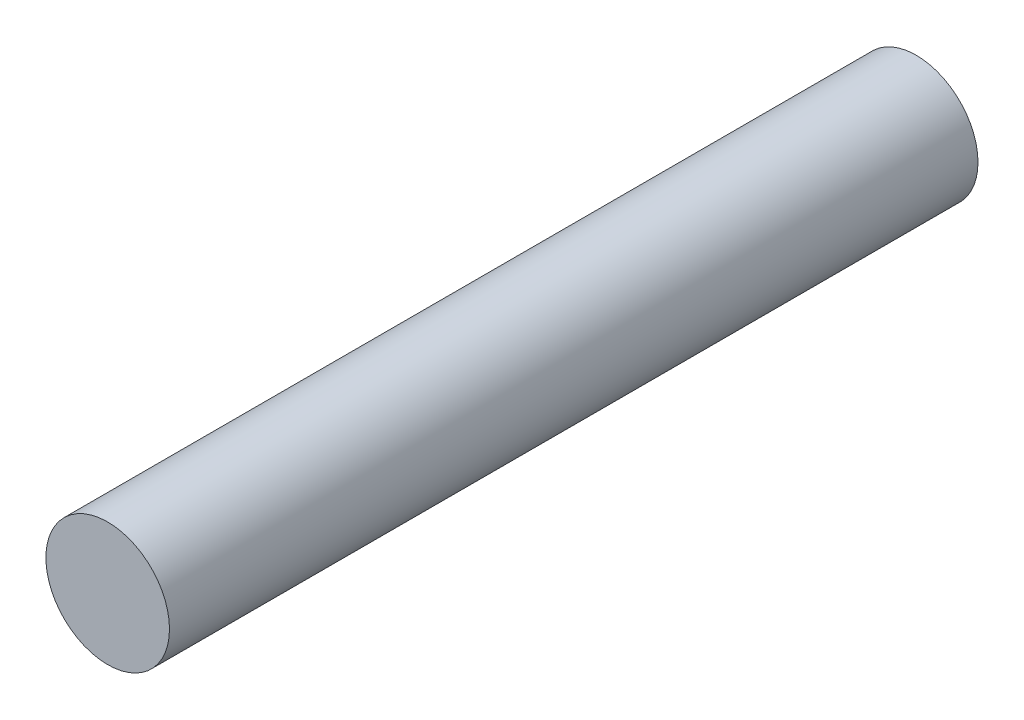
from build123d import *

# Parameters (mm, degrees)
SKETCH1_R           = 6
BOSS_EXTRUDE1_DEPTH = 78.5
SKETCH2_R           = 4.5
CUT_EXTRUDE1_DEPTH  = 2.4


with BuildPart() as part:
    # Sketch1 → Boss-Extrude1 (new body)
    with BuildSketch(Plane.XY):
        Circle(SKETCH1_R)
    extrude(amount=BOSS_EXTRUDE1_DEPTH)

    # Sketch2 → Cut-Extrude1 (cut)
    with BuildSketch(Plane(origin=(0, 0, 0), x_dir=(-1, 0, 0), z_dir=(0, 0, -1))):
        Circle(SKETCH2_R)
    extrude(amount=-CUT_EXTRUDE1_DEPTH, mode=Mode.SUBTRACT)


solid = part.part
